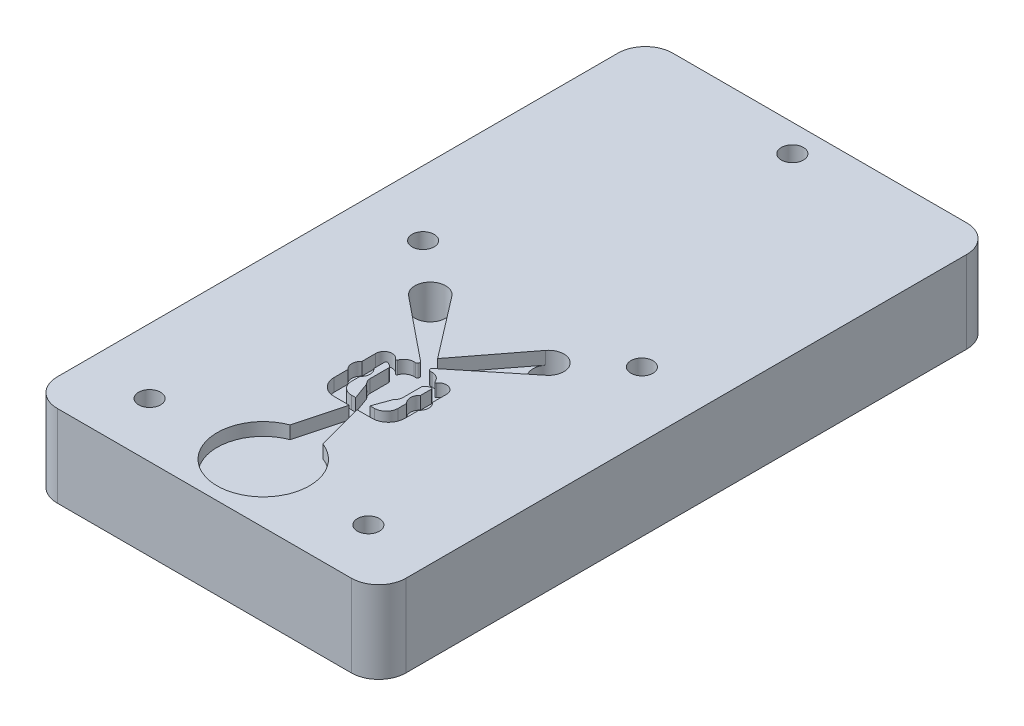
from build123d import *

# Parameters (mm, degrees)
SKETCH1_W                  = 107.95
SKETCH1_H                  = 190.5
BOSS_EXTRUDE1_DEPTH        = 12.7
CUT_EXTRUDE1_START         = 12.7
SKETCH2_R                  = 4.7625
CUT_EXTRUDE1_DEPTH         = 3.9624
CUT_EXTRUDE2_START         = -12.7
SKETCH3_R                  = 4.7625
CUT_EXTRUDE2_DEPTH         = 14.6812
SKETCH5_R                  = 4.7625
CUT_EXTRUDE3_DEPTH         = 22.4376
SCALE1_SCALE               = 0.75
SKETCH6_R                  = 2.1336
CUT_EXTRUDE4_DEPTH         = 2.9718
F_10_CLEARANCE_HOLE1_D     = 5.1054
F_10_CLEARANCE_HOLE1_DEPTH = 19.05
FILLET1_R                  = 6.35


with BuildPart() as part:
    # Sketch1 → Boss-Extrude1 (new body, symmetric)
    with BuildSketch(Plane(origin=(0, 0, 0), x_dir=(1, 0, 0), z_dir=(0, 1, 0))):
        with Locations((0, 49.1998)):
            Rectangle(SKETCH1_W, SKETCH1_H)
    extrude(amount=BOSS_EXTRUDE1_DEPTH, both=True)

    # Sketch2 → Cut-Extrude1 (cut)
    with BuildSketch(Plane(origin=(0, 0, 0), x_dir=(1, 0, 0), z_dir=(0, 1, 0)).offset(CUT_EXTRUDE1_START)):
        with BuildLine():
            Line((5.057939535, -14.433014335), (1.190625, 0))
            Line((1.190625, 0), (5.880526895, 0))
            ThreePointArc((5.880526895, 0), (9.472629344, 1.487897552), (10.960526895, 5.08))
            Line((10.960526895, 5.08), (10.960526895, 17.9832))
            ThreePointArc((10.960526895, 17.9832), (9.213211561, 20.396341318), (6.375289871, 19.48938907))
            ThreePointArc((6.375289871, 19.48938907), (6.062916501, 19.358283139), (5.799480669, 19.571279501))
            ThreePointArc((5.799480669, 19.571279501), (4.636397175, 21.079630515), (2.8194, 21.650951144))
            Line((2.8194, 21.650951144), (2.286, 21.650951144))
            ThreePointArc((2.286, 21.650951144), (1.687422653, 22.073983788), (1.886381552, 22.779438829))
            Line((1.886381552, 22.779438829), (21.285138362, 38.488242359))
            ThreePointArc((21.285138362, 38.488242359), (14.964772935, 38.778011994), (14.509654717, 45.088626306))
            Line((14.509654717, 45.088626306), (0, 26.179276127))
            Line((0, 26.179276127), (0, -13.507771027))
            ThreePointArc((0, -13.507771027), (2.570935021, -13.740985226), (5.057939535, -14.433014335))
        make_face()
        with BuildLine():
            Line((3.543726895, 3.048), (2.2225, 3.048))
            Line((2.2225, 3.048), (4.114068772, 8.245042489))
            ThreePointArc((4.114068772, 8.245042489), (4.191366172, 8.399928267), (4.301626576, 8.533371646))
            ThreePointArc((4.301626576, 8.533371646), (4.877320207, 9.368949404), (5.08, 10.3632))
            Line((5.08, 10.3632), (5.08, 16.267431628))
            ThreePointArc((5.08, 16.267431628), (5.809057387, 17.017360952), (6.778491601, 17.40993702))
            ThreePointArc((6.778491601, 17.40993702), (7.090210384, 17.327130128), (7.226726895, 17.034916467))
            Line((7.226726895, 17.034916467), (7.226726895, 6.731))
            ThreePointArc((7.226726895, 6.731), (6.14800117, 4.126725725), (3.543726895, 3.048))
        make_face(mode=Mode.SUBTRACT)
        with Locations((18.288, 42.1894)):
            Circle(SKETCH2_R)
        with BuildLine():
            ThreePointArc((14.2875, -27.795271027), (11.755806382, -19.67531582), (5.057939535, -14.433014335))
            ThreePointArc((5.057939535, -14.433014335), (2.570935021, -13.740985226), (0, -13.507771027))
            Line((0, -13.507771027), (0, -42.082771027))
            ThreePointArc((0, -42.082771027), (10.102788136, -37.898059163), (14.2875, -27.795271027))
        make_face()
    cut_extrude1 = extrude(amount=-CUT_EXTRUDE1_DEPTH, mode=Mode.SUBTRACT)

    # Sketch3 → Cut-Extrude2 (cut)
    with BuildSketch(Plane(origin=(0, 0, 0), x_dir=(1, 0, 0), z_dir=(0, 1, 0)).offset(CUT_EXTRUDE2_START)):
        with BuildLine():
            Line((12.5222, -2.214016109), (4.623727363, 34.945376076))
            ThreePointArc((4.623727363, 34.945376076), (4.751363404, 35.477018448), (5.24485109, 35.7124))
            Line((5.24485109, 35.7124), (14.342303959, 35.7124))
            ThreePointArc((14.342303959, 35.7124), (18.391335215, 36.554087605), (21.769496507, 38.939694118))
            ThreePointArc((21.769496507, 38.939694118), (14.767691653, 38.981778546), (15.375216855, 45.957304006))
            ThreePointArc((15.375216855, 45.957304006), (11.098329565, 43.715563082), (6.311655978, 43.079227305))
            ThreePointArc((6.311655978, 43.079227305), (5.570694317, 43.539610738), (5.580103416, 44.4119))
            Line((5.580103416, 44.4119), (45.923522628, 114.288751826))
            ThreePointArc((45.923522628, 114.288751826), (40.292251924, 132.148860722), (22.990903716, 124.982407647))
            Line((22.990903716, 124.982407647), (0, 61.815418834))
            Line((0, 61.815418834), (0, 1.6764))
            ThreePointArc((0, 1.6764), (6.556310516, 0.681394963), (12.5222, -2.214016109))
        make_face()
        with Locations((18.288, 42.1894)):
            Circle(SKETCH3_R)
        with BuildLine():
            ThreePointArc((22.098, -20.4216), (19.558082467, -10.135540784), (12.5222, -2.214016109))
            ThreePointArc((12.5222, -2.214016109), (6.556310516, 0.681394963), (0, 1.6764))
            Line((0, 1.6764), (0, -42.5196))
            ThreePointArc((0, -42.5196), (15.625645651, -36.047245651), (22.098, -20.4216))
        make_face()
    cut_extrude2 = extrude(amount=CUT_EXTRUDE2_DEPTH, mode=Mode.SUBTRACT)

    # Sketch5 → Cut-Extrude3 (cut, through all)
    with BuildSketch(Plane(origin=(0, 8.7376, 0), x_dir=(1, 0, 0), z_dir=(0, 1, 0))):
        with Locations((18.288, 42.1894)):
            Circle(SKETCH5_R)
    cut_extrude3 = extrude(amount=-CUT_EXTRUDE3_DEPTH, mode=Mode.SUBTRACT)

    # Mirror1: Cut-Extrude1, Cut-Extrude2, Cut-Extrude3 across plane
    add(cut_extrude1.mirror(Plane(origin=(0, 0, 0), x_dir=(0, 0, 1), z_dir=(1, 0, 0))), mode=Mode.SUBTRACT)
    add(cut_extrude2.mirror(Plane(origin=(0, 0, 0), x_dir=(0, 0, 1), z_dir=(1, 0, 0))), mode=Mode.SUBTRACT)
    add(cut_extrude3.mirror(Plane(origin=(0, 0, 0), x_dir=(0, 0, 1), z_dir=(1, 0, 0))), mode=Mode.SUBTRACT)


with BuildPart() as part_1:
    # Scale1: scaled about (0, 0.932530252, -48.998072256)
    add(part.part.scale(SCALE1_SCALE).moved(Location((0, 0.233132563, -12.249518064))))

    # Sketch6 → Cut-Extrude4 (cut)
    with BuildSketch(Plane(origin=(0, 9.758132563, 0), x_dir=(1, 0, 0), z_dir=(0, 1, 0))):
        with Locations((-6.820220171, 20.898218064)):
            Circle(SKETCH6_R)
        with Locations((6.820220171, 20.898218064)):
            Circle(SKETCH6_R)
    extrude(amount=-CUT_EXTRUDE4_DEPTH, mode=Mode.SUBTRACT)

    # #10 Clearance Hole1
    with Locations(Plane(origin=(0, 9.758132563, 0), x_dir=(1, 0, 0), z_dir=(0, 1, 0))):
        with Locations((0, 114.236868064), (-25.4, 53.911868064), (25.4, 53.911868064), (25.4, -9.588131936), (-25.4, -9.588131936)):
            Hole(F_10_CLEARANCE_HOLE1_D / 2, depth=F_10_CLEARANCE_HOLE1_DEPTH)

    # Fillet1
    fillet1_edges = [part_1.edges().sort_by_distance(p)[0] for p in [
        (-40.48125, 0.233132563, -120.586868064),
        (40.48125, 0.233132563, -120.586868064),
        (40.48125, 0.233132563, 22.288131936),
        (-40.48125, 0.233132563, 22.288131936),
    ]]
    fillet(fillet1_edges, radius=FILLET1_R)


solid = part_1.part
